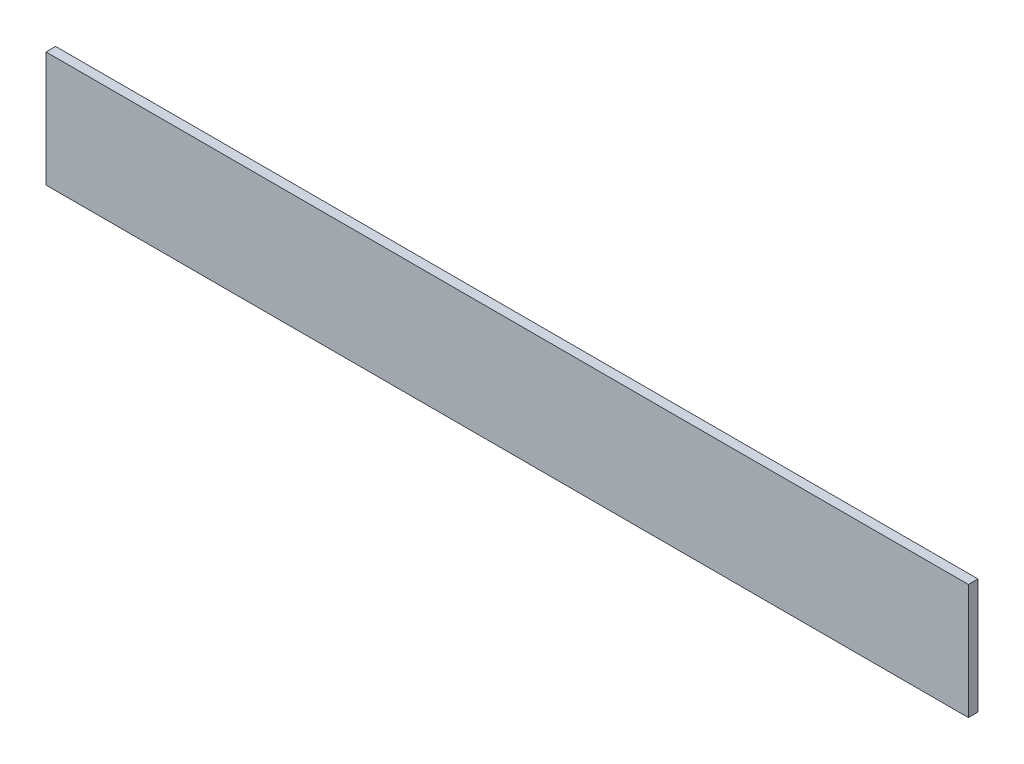
from build123d import *

# Parameters (mm, degrees)
SKETCH1_W           = 609.6
SKETCH1_H           = 76.2
BOSS_EXTRUDE1_DEPTH = 6.35


with BuildPart() as part:
    # Sketch1 → Boss-Extrude1 (new body)
    with BuildSketch(Plane.XY):
        Rectangle(SKETCH1_W, SKETCH1_H)
    extrude(amount=BOSS_EXTRUDE1_DEPTH)


solid = part.part
